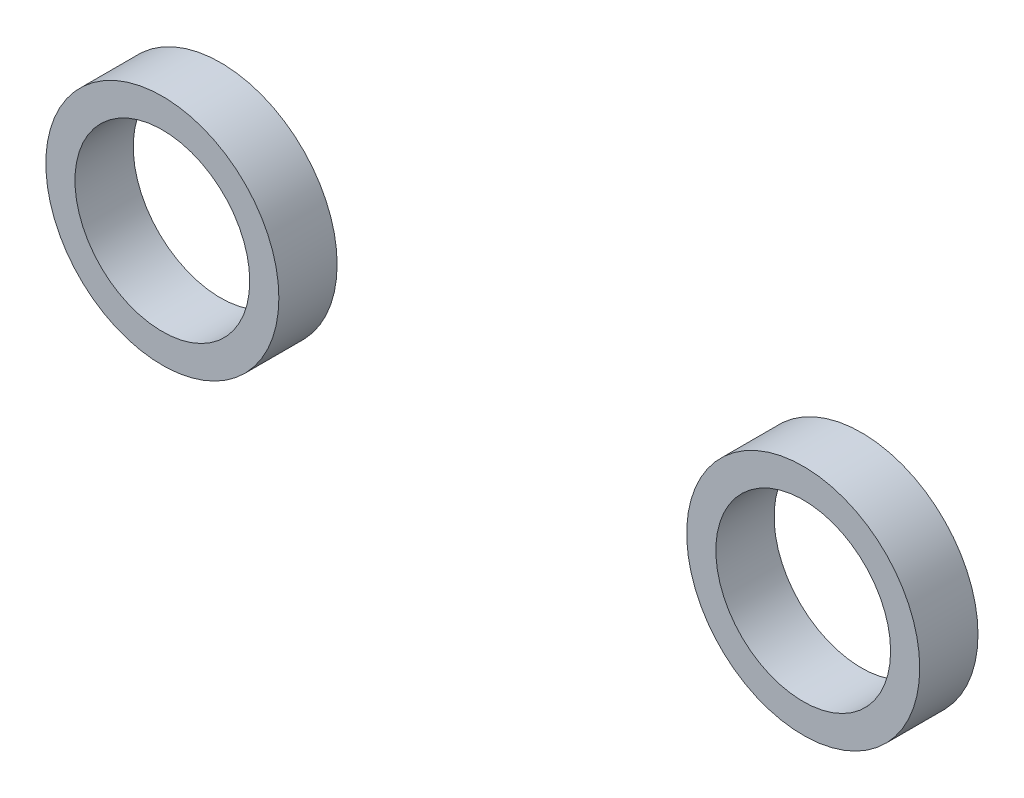
from build123d import *

# Parameters (mm, degrees)
SKETCH3_R             = 2.54
SKETCH3_R_2           = 1.905
BOSS_EXTRUDE1_DEPTH   = 1.27
BOSS_EXTRUDE1_2_DEPTH = 1.27


with BuildPart() as part:
    # Sketch3 → Boss-Extrude1 (new body)
    with BuildSketch(Plane.XY):
        with Locations((33.287368421, 165.1)):
            Circle(SKETCH3_R)
        with Locations((33.287368421, 165.1)):
            Circle(SKETCH3_R_2, mode=Mode.SUBTRACT)
    extrude(amount=BOSS_EXTRUDE1_DEPTH)


with BuildPart() as body_2:
    # Sketch3 → Boss-Extrude1 2 (new body)
    with BuildSketch(Plane.XY):
        with Locations((47.257368421, 165.1)):
            Circle(SKETCH3_R)
        with Locations((47.257368421, 165.1)):
            Circle(SKETCH3_R_2, mode=Mode.SUBTRACT)
    extrude(amount=BOSS_EXTRUDE1_2_DEPTH)


solid = Compound([part.part, body_2.part])
